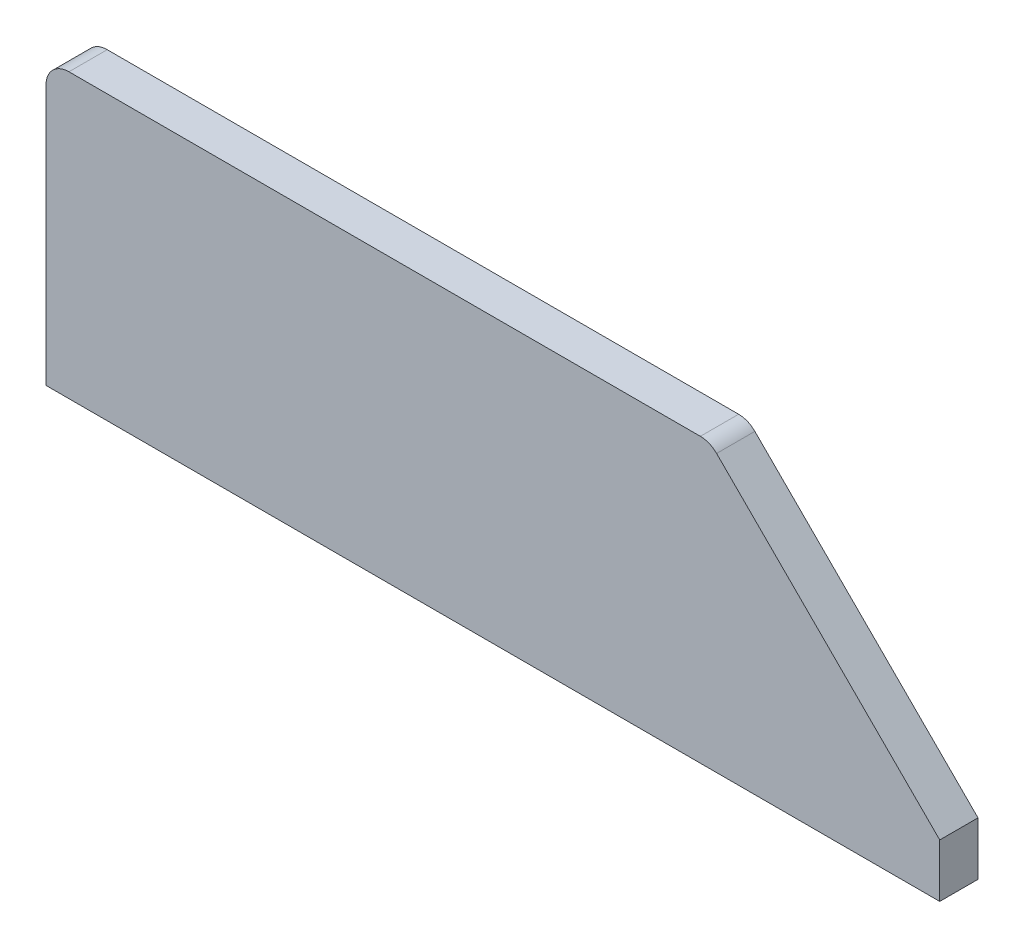
from build123d import *

# Parameters (mm, degrees)
SALIENTE_EXTRUIR1_DEPTH = 5


with BuildPart() as part:
    # Croquis1 → Saliente-Extruir1 (new body)
    with BuildSketch(Plane.XY):
        with BuildLine():
            Line((87.636038969, 36.121320344), (116.796683693, 6.96067562))
            Line((116.796683693, 6.96067562), (116.796683693, 0))
            Line((116.796683693, 0), (0, 0))
            Line((0, 0), (0, 34))
            ThreePointArc((0, 34), (0.878679656, 36.121320344), (3, 37))
            Line((3, 37), (85.514718626, 37))
            ThreePointArc((85.514718626, 37), (86.662768923, 36.771638598), (87.636038969, 36.121320344))
        make_face()
    extrude(amount=SALIENTE_EXTRUIR1_DEPTH)


solid = part.part
